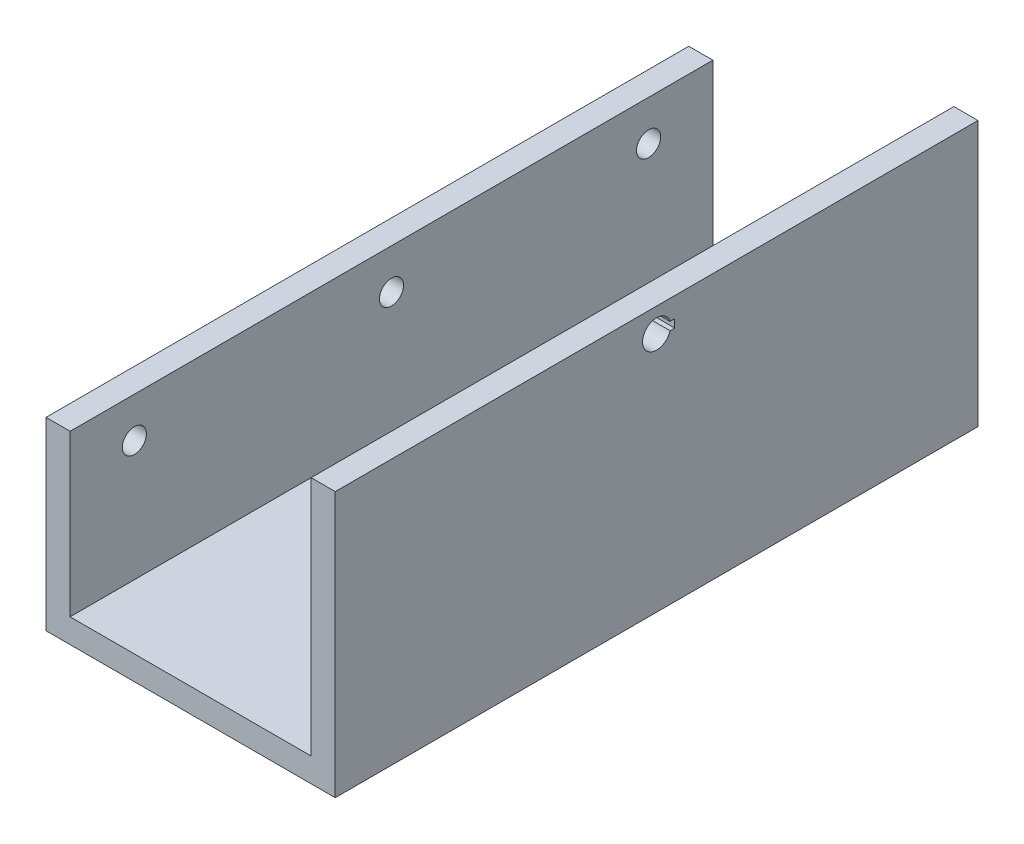
from build123d import *

# Parameters (mm, degrees)
SKETCH2_W           = 30
SKETCH2_H           = 30
SKETCH2_R           = 1.75
BOSS_EXTRUDE1_DEPTH = 2
SKETCH3_W           = 30
SKETCH3_H           = 3
BOSS_EXTRUDE2_DEPTH = 76
SKETCH7_R           = 4
CUT_EXTRUDE1_DEPTH  = 3
SKETCH8_W           = 30
SKETCH8_H           = 2
CUT_EXTRUDE2_DEPTH  = 27
SKETCH9_W           = 3
SKETCH9_H           = 80
BOSS_EXTRUDE3_DEPTH = 33
SKETCH10_R          = 1.75
CUT_EXTRUDE3_DEPTH  = 37
CUT_EXTRUDE4_DEPTH  = 50
CUT_EXTRUDE5_REACH  = 38
SKETCH12_W          = 80
SKETCH12_H          = 10
SKETCH13_R          = 1.5
CUT_EXTRUDE6_DEPTH  = 6


with BuildPart() as part:
    # Sketch2 → Boss-Extrude1 (new body)
    with BuildSketch(Plane.XY):
        with Locations((-15, -15)):
            Rectangle(SKETCH2_W, SKETCH2_H)
        with Locations((-15, -2.5)):
            Circle(SKETCH2_R, mode=Mode.SUBTRACT)
    boss_extrude1 = extrude(amount=BOSS_EXTRUDE1_DEPTH)

    # Sketch3 → Boss-Extrude2 (add)
    with BuildSketch(Plane.XY.offset(2)):
        with Locations((-15, -28.5)):
            Rectangle(SKETCH3_W, SKETCH3_H)
    extrude(amount=BOSS_EXTRUDE2_DEPTH)

    # Mirror1: Boss-Extrude1 across plane
    add(boss_extrude1.mirror(Plane.XY.offset(40)))

    # Sketch7 → Cut-Extrude1 (cut)
    with BuildSketch(Plane(origin=(-25.653020371, -30, -8.772654641), x_dir=(1, 0, 0), z_dir=(0, -1, 0))):
        with Locations((10.653020371, 28.302654641)):
            Circle(SKETCH7_R)
    extrude(amount=-CUT_EXTRUDE1_DEPTH, mode=Mode.SUBTRACT)

    # Sketch8 → Cut-Extrude2 (cut)
    with BuildSketch(Plane(origin=(0, 0, 0), x_dir=(1, 0, 0), z_dir=(0, 1, 0))):
        with Locations((-15, -79)):
            Rectangle(SKETCH8_W, SKETCH8_H)
        with Locations((-15, -1)):
            Rectangle(SKETCH8_W, SKETCH8_H)
    extrude(amount=-CUT_EXTRUDE2_DEPTH, mode=Mode.SUBTRACT)

    # Sketch9 → Boss-Extrude3 (add)
    with BuildSketch(Plane.XZ.offset(30)):
        with Locations((1.5, 40)):
            Rectangle(SKETCH9_W, SKETCH9_H)
        with Locations((-31.5, 40)):
            Rectangle(SKETCH9_W, SKETCH9_H)
    extrude(amount=-BOSS_EXTRUDE3_DEPTH)

    # Sketch10 → Cut-Extrude3 (cut, through all)
    with BuildSketch(Plane.ZY.offset(33)):
        with Locations((40, 0)):
            Circle(SKETCH10_R)
    extrude(amount=-CUT_EXTRUDE3_DEPTH, mode=Mode.SUBTRACT)

    # Sketch11 → Cut-Extrude4 (cut)
    with BuildSketch(Plane(origin=(-33, -23.468882819, -8.772654641), x_dir=(0, 0, 1), z_dir=(-1, 0, 0))):
        with BuildLine():
            Line((47.095603657, 22.968882819), (46.522654641, 22.968882819))
            Line((46.522654641, 22.968882819), (46.522654641, 23.968882819))
            Line((46.522654641, 23.968882819), (47.095603657, 23.968882819))
            ThreePointArc((47.095603657, 23.968882819), (50.522654641, 23.468882819), (47.095603657, 22.968882819))
        make_face()
    extrude(amount=-CUT_EXTRUDE4_DEPTH, mode=Mode.SUBTRACT)

    # Sketch12 → Cut-Extrude5 (cut, up to next)
    with BuildSketch(Plane.ZY.offset(33), mode=Mode.PRIVATE) as cut_extrude5_sk1:
        with Locations((40, -2)):
            Rectangle(SKETCH12_W, SKETCH12_H)
    cut_extrude5_tool1 = extrude(cut_extrude5_sk1.sketch, amount=-CUT_EXTRUDE5_REACH, mode=Mode.PRIVATE) & part.part
    add(cut_extrude5_tool1.solids().sort_by_distance((-33, -2, 40))[0], mode=Mode.SUBTRACT)

    # Sketch13 → Cut-Extrude6 (cut)
    with BuildSketch(Plane(origin=(-36, -23.468882819, -8.772654641), x_dir=(0, 0, 1), z_dir=(-1, 0, 0))):
        with Locations((16.772654641, 11.468882819)):
            Circle(SKETCH13_R)
        with Locations((48.772654641, 11.468882819)):
            Circle(SKETCH13_R)
        with Locations((80.772654641, 11.468882819)):
            Circle(SKETCH13_R)
    extrude(amount=-CUT_EXTRUDE6_DEPTH, mode=Mode.SUBTRACT)


solid = part.part
